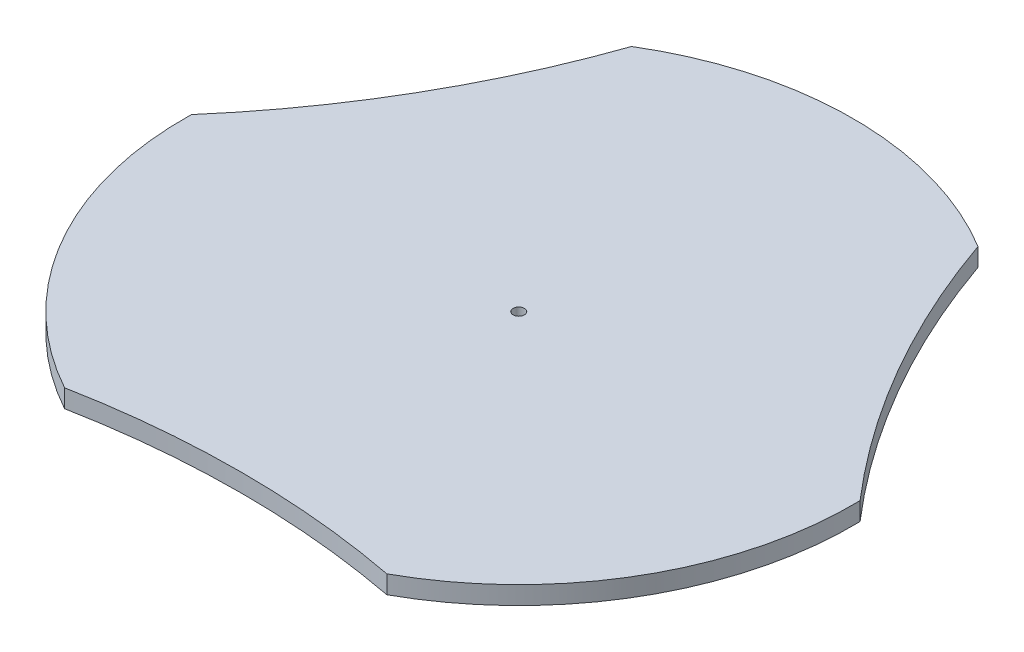
from build123d import *

# Parameters (mm, degrees)
SKETCH1_R           = 37
BOSS_EXTRUDE1_DEPTH = 1.6
SKETCH5_R           = 75.500139874
CUT_EXTRUDE2_DEPTH  = 2.6
SKETCH7_R           = 0.5
CUT_EXTRUDE3_DEPTH  = 2.6
SKETCH3_R           = 1.75
CUT_EXTRUDE4_DEPTH  = 2.6
SKETCH8_R           = 1.65
CUT_EXTRUDE5_DEPTH  = 2.6
CIRPATTERN2_COUNT   = 3
SKETCH10_OUTSIDE_W  = 94.454
SKETCH10_OUTSIDE_H  = 86.922
SKETCH10_OUTSIDE_R  = 29.5
CUT_EXTRUDE7_DEPTH  = 10


with BuildPart() as part:
    # Sketch1 → Boss-Extrude1 (new body)
    with BuildSketch(Plane(origin=(0, 0, 0), x_dir=(1, 0, 0), z_dir=(0, 1, 0))):
        Circle(SKETCH1_R)
    extrude(amount=BOSS_EXTRUDE1_DEPTH)

    # Sketch5 → Cut-Extrude2 (cut, through all)
    with BuildSketch(Plane(origin=(0, 1.6, 0), x_dir=(1, 0, 0), z_dir=(0, 1, 0))):
        with Locations((86.602540378, 50)):
            Circle(SKETCH5_R)
    cut_extrude2 = extrude(amount=-CUT_EXTRUDE2_DEPTH, mode=Mode.SUBTRACT)

    # Sketch7 → Cut-Extrude3 (cut, through all)
    with BuildSketch(Plane(origin=(0, 1.6, 0), x_dir=(1, 0, 0), z_dir=(0, 1, 0))):
        Circle(SKETCH7_R)
    extrude(amount=-CUT_EXTRUDE3_DEPTH, mode=Mode.SUBTRACT)

    # Sketch3 → Cut-Extrude4 (cut, through all)
    with BuildSketch(Plane(origin=(0, 1.6, 0), x_dir=(1, 0, 0), z_dir=(0, 1, 0))):
        with Locations((2.788983768, 31.878230339)):
            Circle(SKETCH3_R)
        with Locations((26.212865417, -18.354445963)):
            Circle(SKETCH3_R)
        with Locations((-29.001849185, -13.523784376)):
            Circle(SKETCH3_R)
    extrude(amount=-CUT_EXTRUDE4_DEPTH, mode=Mode.SUBTRACT)

    # Sketch8 → Cut-Extrude5 (cut, through all)
    with BuildSketch(Plane(origin=(0, 1.6, 0), x_dir=(1, 0, 0), z_dir=(0, 1, 0))):
        with Locations((-5.904038041, 33.483463602)):
            Circle(SKETCH8_R)
    cut_extrude5 = extrude(amount=-CUT_EXTRUDE5_DEPTH, mode=Mode.SUBTRACT)

    # CirPattern2: Cut-Extrude2, Cut-Extrude5 ×3 about axis
    cirpattern2_axis = Axis((0, 0, 0), (0, 1, 0))
    for i in range(1, CIRPATTERN2_COUNT):
        add(cut_extrude2.rotate(cirpattern2_axis, i * 360 / CIRPATTERN2_COUNT), mode=Mode.SUBTRACT)
        add(cut_extrude5.rotate(cirpattern2_axis, i * 360 / CIRPATTERN2_COUNT), mode=Mode.SUBTRACT)

    # Sketch10 outside → Cut-Extrude7 (cut)
    with BuildSketch(Plane(origin=(0, 1.6, 0), x_dir=(1, 0, 0), z_dir=(0, 1, 0))):
        with Locations((0, 4.328)):
            Rectangle(SKETCH10_OUTSIDE_W, SKETCH10_OUTSIDE_H)
        Circle(SKETCH10_OUTSIDE_R, mode=Mode.SUBTRACT)
    extrude(amount=-CUT_EXTRUDE7_DEPTH, mode=Mode.SUBTRACT)


solid = part.part
